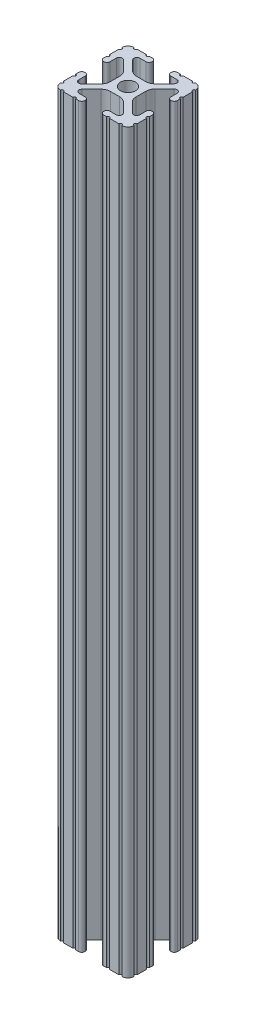
from build123d import *

# Parameters (mm, degrees)
SKETCH1_R           = 2.6035
BOSS_EXTRUDE1_DEPTH = 127


with BuildPart() as part:
    # Sketch1 → Boss-Extrude1 (new body, symmetric)
    with BuildSketch(Plane(origin=(0, 0, 0), x_dir=(0, 0, -1), z_dir=(0, 1, 0))):
        with BuildLine():
            Line((6.333126718, -12.7), (9.550443118, -12.7))
            ThreePointArc((9.550443118, -12.7), (10.058366869, -12.192000006), (10.566443095, -12.699847501))
            ThreePointArc((10.566443095, -12.699847501), (12.082537762, -12.08250727), (12.699846982, -10.566399977))
            ThreePointArc((12.699846982, -10.566399977), (12.192000006, -10.058323491), (12.7, -9.5504))
            Line((12.7, -9.5504), (12.7, -6.3330836))
            ThreePointArc((12.7, -6.3330836), (12.192, -5.8250836), (12.7, -5.3170836))
            Line((12.7, -5.3170836), (12.7, -4.287469289))
            ThreePointArc((12.7, -4.287469289), (12.39275138, -3.545705502), (11.650987593, -3.238456882))
            Line((11.650987593, -3.238456882), (11.539212407, -3.238456882))
            ThreePointArc((11.539212407, -3.238456882), (10.79744862, -3.545705502), (10.4902, -4.287469289))
            Line((10.4902, -4.287469289), (10.4902, -6.402089023))
            ThreePointArc((10.4902, -6.402089023), (9.856505071, -7.351067942), (8.737131347, -7.129408934))
            Line((8.737131347, -7.129408934), (5.441005833, -3.840816462))
            ThreePointArc((5.441005833, -3.840816462), (4.750877967, -2.809883091), (4.5085, -1.593185507))
            Line((4.5085, -1.593185507), (4.5085, 1.593185507))
            ThreePointArc((4.5085, 1.593185507), (4.750877967, 2.809883091), (5.441005833, 3.840816462))
            Line((5.441005833, 3.840816462), (8.737131347, 7.129408934))
            ThreePointArc((8.737131347, 7.129408934), (9.856505071, 7.351067942), (10.4902, 6.402089023))
            Line((10.4902, 6.402089023), (10.4902, 4.287469289))
            ThreePointArc((10.4902, 4.287469289), (10.79744862, 3.545705502), (11.539212407, 3.238456882))
            Line((11.539212407, 3.238456882), (11.650987593, 3.238456882))
            ThreePointArc((11.650987593, 3.238456882), (12.39275138, 3.545705502), (12.7, 4.287469289))
            Line((12.7, 4.287469289), (12.7, 5.3170836))
            ThreePointArc((12.7, 5.3170836), (12.192, 5.8250836), (12.7, 6.3330836))
            Line((12.7, 6.3330836), (12.7, 9.5504))
            ThreePointArc((12.7, 9.5504), (12.192000006, 10.058323491), (12.699846982, 10.566399977))
            ThreePointArc((12.699846982, 10.566399977), (12.082537762, 12.08250727), (10.566443095, 12.699847501))
            ThreePointArc((10.566443095, 12.699847501), (10.058366869, 12.192000006), (9.550443118, 12.7))
            Line((9.550443118, 12.7), (6.333126718, 12.7))
            ThreePointArc((6.333126718, 12.7), (5.825126718, 12.192), (5.317126718, 12.7))
            Line((5.317126718, 12.7), (4.287512407, 12.7))
            ThreePointArc((4.287512407, 12.7), (3.54574862, 12.39275138), (3.2385, 11.650987593))
            Line((3.2385, 11.650987593), (3.2385, 11.539212407))
            ThreePointArc((3.2385, 11.539212407), (3.54574862, 10.79744862), (4.287512407, 10.4902))
            Line((4.287512407, 10.4902), (6.476788598, 10.4902))
            ThreePointArc((6.476788598, 10.4902), (7.432222385, 9.85140422), (7.207036008, 8.724370562))
            Line((7.207036008, 8.724370562), (3.898272566, 5.423169045))
            ThreePointArc((3.898272566, 5.423169045), (2.869120213, 4.736787962), (1.655778399, 4.4958))
            Line((1.655778399, 4.4958), (-1.655778399, 4.4958))
            ThreePointArc((-1.655778399, 4.4958), (-2.869120213, 4.736787962), (-3.898272566, 5.423169045))
            Line((-3.898272566, 5.423169045), (-7.207036008, 8.724370562))
            ThreePointArc((-7.207036008, 8.724370562), (-7.432222385, 9.85140422), (-6.476788598, 10.4902))
            Line((-6.476788598, 10.4902), (-4.287512407, 10.4902))
            ThreePointArc((-4.287512407, 10.4902), (-3.54574862, 10.79744862), (-3.2385, 11.539212407))
            Line((-3.2385, 11.539212407), (-3.2385, 11.650987593))
            ThreePointArc((-3.2385, 11.650987593), (-3.54574862, 12.39275138), (-4.287512407, 12.7))
            Line((-4.287512407, 12.7), (-5.317126718, 12.7))
            ThreePointArc((-5.317126718, 12.7), (-5.825126718, 12.192), (-6.333126718, 12.7))
            Line((-6.333126718, 12.7), (-9.550443118, 12.7))
            ThreePointArc((-9.550443118, 12.7), (-10.058366869, 12.192000006), (-10.566443095, 12.699847501))
            ThreePointArc((-10.566443095, 12.699847501), (-12.082537762, 12.08250727), (-12.699846982, 10.566399977))
            ThreePointArc((-12.699846982, 10.566399977), (-12.192000006, 10.058323491), (-12.7, 9.5504))
            Line((-12.7, 9.5504), (-12.7, 6.3330836))
            ThreePointArc((-12.7, 6.3330836), (-12.192, 5.8250836), (-12.7, 5.3170836))
            Line((-12.7, 5.3170836), (-12.7, 4.287469289))
            ThreePointArc((-12.7, 4.287469289), (-12.39275138, 3.545705502), (-11.650987593, 3.238456882))
            Line((-11.650987593, 3.238456882), (-11.539212407, 3.238456882))
            ThreePointArc((-11.539212407, 3.238456882), (-10.79744862, 3.545705502), (-10.4902, 4.287469289))
            Line((-10.4902, 4.287469289), (-10.4902, 6.402089023))
            ThreePointArc((-10.4902, 6.402089023), (-9.856505071, 7.351067942), (-8.737131347, 7.129408934))
            Line((-8.737131347, 7.129408934), (-5.441005833, 3.840816462))
            ThreePointArc((-5.441005833, 3.840816462), (-4.750877967, 2.809883091), (-4.5085, 1.593185507))
            Line((-4.5085, 1.593185507), (-4.5085, -1.593185507))
            ThreePointArc((-4.5085, -1.593185507), (-4.750877967, -2.809883091), (-5.441005833, -3.840816462))
            Line((-5.441005833, -3.840816462), (-8.737131347, -7.129408934))
            ThreePointArc((-8.737131347, -7.129408934), (-9.856505071, -7.351067942), (-10.4902, -6.402089023))
            Line((-10.4902, -6.402089023), (-10.4902, -4.287469289))
            ThreePointArc((-10.4902, -4.287469289), (-10.79744862, -3.545705502), (-11.539212407, -3.238456882))
            Line((-11.539212407, -3.238456882), (-11.650987593, -3.238456882))
            ThreePointArc((-11.650987593, -3.238456882), (-12.39275138, -3.545705502), (-12.7, -4.287469289))
            Line((-12.7, -4.287469289), (-12.7, -5.3170836))
            ThreePointArc((-12.7, -5.3170836), (-12.192, -5.8250836), (-12.7, -6.3330836))
            Line((-12.7, -6.3330836), (-12.7, -9.5504))
            ThreePointArc((-12.7, -9.5504), (-12.192000006, -10.058323491), (-12.699846982, -10.566399977))
            ThreePointArc((-12.699846982, -10.566399977), (-12.082537762, -12.08250727), (-10.566443095, -12.699847501))
            ThreePointArc((-10.566443095, -12.699847501), (-10.058366869, -12.192000006), (-9.550443118, -12.7))
            Line((-9.550443118, -12.7), (-6.333126718, -12.7))
            ThreePointArc((-6.333126718, -12.7), (-5.825126718, -12.192), (-5.317126718, -12.7))
            Line((-5.317126718, -12.7), (-4.287512407, -12.7))
            ThreePointArc((-4.287512407, -12.7), (-3.54574862, -12.39275138), (-3.2385, -11.650987593))
            Line((-3.2385, -11.650987593), (-3.2385, -11.539212407))
            ThreePointArc((-3.2385, -11.539212407), (-3.54574862, -10.79744862), (-4.287512407, -10.4902))
            Line((-4.287512407, -10.4902), (-6.416408329, -10.4902))
            ThreePointArc((-6.416408329, -10.4902), (-7.41473083, -9.822813117), (-7.179650497, -8.645192506))
            Line((-7.179650497, -8.645192506), (-3.952270251, -5.423690499))
            ThreePointArc((-3.952270251, -5.423690499), (-2.922936451, -4.736929036), (-1.709253557, -4.4958))
            Line((-1.709253557, -4.4958), (1.709253557, -4.4958))
            ThreePointArc((1.709253557, -4.4958), (2.922936451, -4.736929036), (3.952270251, -5.423690499))
            Line((3.952270251, -5.423690499), (7.179650497, -8.645192506))
            ThreePointArc((7.179650497, -8.645192506), (7.41473083, -9.822813117), (6.416408329, -10.4902))
            Line((6.416408329, -10.4902), (4.287512407, -10.4902))
            ThreePointArc((4.287512407, -10.4902), (3.54574862, -10.79744862), (3.2385, -11.539212407))
            Line((3.2385, -11.539212407), (3.2385, -11.650987593))
            ThreePointArc((3.2385, -11.650987593), (3.54574862, -12.39275138), (4.287512407, -12.7))
            Line((4.287512407, -12.7), (5.317126718, -12.7))
            ThreePointArc((5.317126718, -12.7), (5.825126718, -12.192), (6.333126718, -12.7))
        make_face()
        Circle(SKETCH1_R, mode=Mode.SUBTRACT)
    extrude(amount=BOSS_EXTRUDE1_DEPTH, both=True)


solid = part.part
